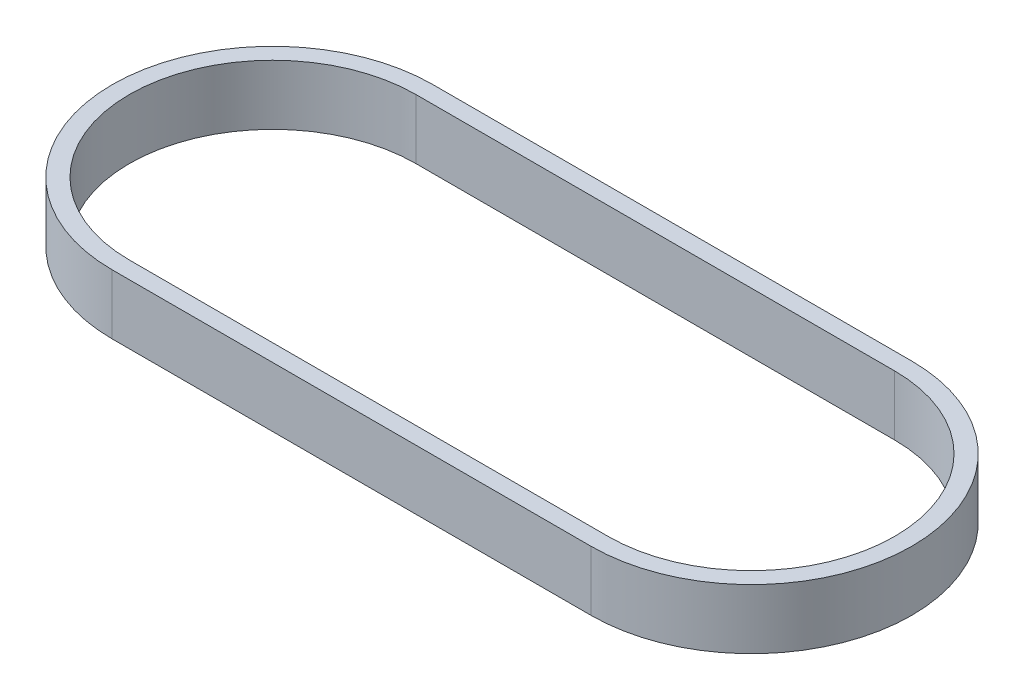
from build123d import *

# Parameters (mm, degrees)
EXTRUDE_1_DEPTH = 7


with BuildPart() as part:
    # 草图2 → 拉伸-薄壁1 (new body)
    with BuildSketch(Plane(origin=(0, 0, 0), x_dir=(1, 0, 0), z_dir=(0, 1, 0))):
        with BuildLine():
            Line((56, -18.76), (0, -18.76))
            ThreePointArc((0, -18.76), (-18.76, 0), (0, 18.76))
            Line((0, 18.76), (56, 18.76))
            ThreePointArc((56, 18.76), (74.76, 0), (56, -18.76))
        make_face()
        with BuildLine():
            Line((56, -16.76), (0, -16.76))
            ThreePointArc((0, -16.76), (-16.76, 0), (0, 16.76))
            Line((0, 16.76), (56, 16.76))
            ThreePointArc((56, 16.76), (72.76, 0), (56, -16.76))
        make_face(mode=Mode.SUBTRACT)
    extrude(amount=EXTRUDE_1_DEPTH)


solid = part.part
